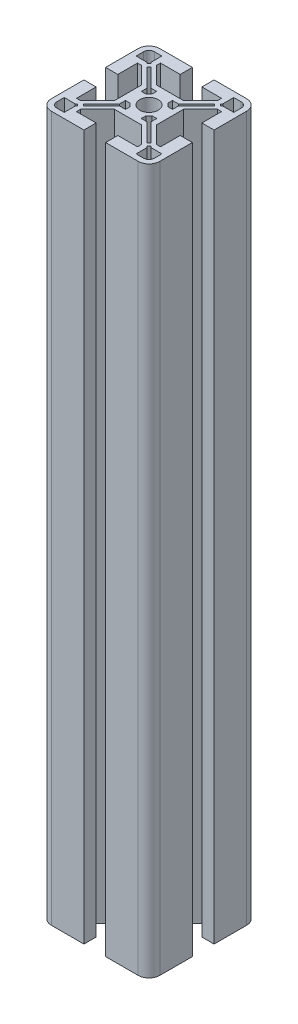
from build123d import *

# Parameters (mm, degrees)
BOSS_EXTRUDE1_DEPTH = 130


with BuildPart() as part:
    # Sketch1 → Boss-Extrude1 (new body, symmetric)
    with BuildSketch(Plane(origin=(0, 0, 0), x_dir=(1, 0, 0), z_dir=(0, 1, 0))):
        with BuildLine():
            Line((-27.932619, -6.859853), (-27.932619, 5.140147))
            ThreePointArc((-27.932619, 5.140147), (-26.761046, 7.968574), (-23.932619, 9.140147))
            Line((-23.932619, 9.140147), (-11.932619, 9.140147))
            Line((-11.932619, 9.140147), (-11.932619, 4.640147))
            Line((-11.932619, 4.640147), (-19.182619, 4.640147))
            Line((-19.182619, 4.640147), (-19.182619, 3.140147))
            Line((-19.182619, 3.140147), (-12.932619, -3.109853))
            Line((-12.932619, -3.109853), (-7.932619, -3.109853))
            Line((-7.932619, -3.109853), (-2.932619, -3.109853))
            Line((-2.932619, -3.109853), (3.317381, 3.140147))
            Line((3.317381, 3.140147), (3.317381, 4.640147))
            Line((3.317381, 4.640147), (-3.932619, 4.640147))
            Line((-3.932619, 4.640147), (-3.932619, 9.140147))
            Line((-3.932619, 9.140147), (8.067381, 9.140147))
            ThreePointArc((8.067381, 9.140147), (10.895808, 7.968574), (12.067381, 5.140147))
            Line((12.067381, 5.140147), (12.067381, -6.859853))
            Line((12.067381, -6.859853), (7.567381, -6.859853))
            Line((7.567381, -6.859853), (7.567381, 0.390147))
            Line((7.567381, 0.390147), (6.067381, 0.390147))
            Line((6.067381, 0.390147), (-0.182619, -5.859853))
            Line((-0.182619, -5.859853), (-0.182619, -10.859853))
            Line((-0.182619, -10.859853), (-0.182619, -15.859853))
            Line((-0.182619, -15.859853), (6.067381, -22.109853))
            Line((6.067381, -22.109853), (7.567381, -22.109853))
            Line((7.567381, -22.109853), (7.567381, -14.859853))
            Line((7.567381, -14.859853), (12.067381, -14.859853))
            Line((12.067381, -14.859853), (12.067381, -26.859853))
            ThreePointArc((12.067381, -26.859853), (10.895808, -29.68828), (8.067381, -30.859853))
            Line((8.067381, -30.859853), (-3.932619, -30.859853))
            Line((-3.932619, -30.859853), (-3.932619, -26.359853))
            Line((-3.932619, -26.359853), (3.317381, -26.359853))
            Line((3.317381, -26.359853), (3.317381, -24.859853))
            Line((3.317381, -24.859853), (-2.932619, -18.609853))
            Line((-2.932619, -18.609853), (-7.932619, -18.609853))
            Line((-7.932619, -18.609853), (-12.932619, -18.609853))
            Line((-12.932619, -18.609853), (-19.182619, -24.859853))
            Line((-19.182619, -24.859853), (-19.182619, -26.359853))
            Line((-19.182619, -26.359853), (-11.932619, -26.359853))
            Line((-11.932619, -26.359853), (-11.932619, -30.859853))
            Line((-11.932619, -30.859853), (-23.932619, -30.859853))
            ThreePointArc((-23.932619, -30.859853), (-26.761046, -29.68828), (-27.932619, -26.859853))
            Line((-27.932619, -26.859853), (-27.932619, -14.859853))
            Line((-27.932619, -14.859853), (-23.432619, -14.859853))
            Line((-23.432619, -14.859853), (-23.432619, -22.109853))
            Line((-23.432619, -22.109853), (-21.932619, -22.109853))
            Line((-21.932619, -22.109853), (-15.682619, -15.859853))
            Line((-15.682619, -15.859853), (-15.682619, -10.859853))
            Line((-15.682619, -10.859853), (-15.682619, -5.859853))
            Line((-15.682619, -5.859853), (-21.932619, 0.390147))
            Line((-21.932619, 0.390147), (-23.432619, 0.390147))
            Line((-23.432619, 0.390147), (-23.432619, -6.859853))
            Line((-23.432619, -6.859853), (-27.932619, -6.859853))
        make_face()
        with BuildLine():
            Line((-25.932619, 2.390147), (-25.932619, 5.140147))
            ThreePointArc((-25.932619, 5.140147), (-25.346832, 6.554361), (-23.932619, 7.140147))
            Line((-23.932619, 7.140147), (-21.182619, 7.140147))
            Line((-21.182619, 7.140147), (-21.182619, 3.097254))
            Line((-21.182619, 3.097254), (-20.734396, 2.649031))
            Line((-20.734396, 2.649031), (-21.441502, 1.941924))
            Line((-21.441502, 1.941924), (-21.889726, 2.390147))
            Line((-21.889726, 2.390147), (-25.932619, 2.390147))
        make_face(mode=Mode.SUBTRACT)
        with BuildLine():
            Line((-20.380842, 0.881264), (-13.682619, -5.816959))
            Line((-13.682619, -5.816959), (-13.682619, -7.955115))
            Line((-13.682619, -7.955115), (-13.182619, -7.955115))
            Line((-13.182619, -7.955115), (-12.002324, -7.955115))
            ThreePointArc((-12.002324, -7.955115), (-11.468153, -7.324319), (-10.837356, -6.790148))
            Line((-10.837356, -6.790148), (-10.837356, -5.609853))
            Line((-10.837356, -5.609853), (-10.837356, -5.109853))
            Line((-10.837356, -5.109853), (-12.975512, -5.109853))
            Line((-12.975512, -5.109853), (-19.673735, 1.588371))
            Line((-19.673735, 1.588371), (-20.380842, 0.881264))
        make_face(mode=Mode.SUBTRACT)
        with BuildLine():
            Line((10.067381, 2.390147), (10.067381, 5.140147))
            ThreePointArc((10.067381, 5.140147), (9.481595, 6.554361), (8.067381, 7.140147))
            Line((8.067381, 7.140147), (5.317381, 7.140147))
            Line((5.317381, 7.140147), (5.317381, 3.097254))
            Line((5.317381, 3.097254), (4.869158, 2.649031))
            Line((4.869158, 2.649031), (5.576265, 1.941924))
            Line((5.576265, 1.941924), (6.024488, 2.390147))
            Line((6.024488, 2.390147), (10.067381, 2.390147))
        make_face(mode=Mode.SUBTRACT)
        with BuildLine():
            Line((-2.182619, -5.816959), (-2.182619, -7.955115))
            Line((-2.182619, -7.955115), (-2.682619, -7.955115))
            Line((-2.682619, -7.955115), (-3.862914, -7.955115))
            ThreePointArc((-3.862914, -7.955115), (-4.397085, -7.324319), (-5.027881, -6.790148))
            Line((-5.027881, -6.790148), (-5.027881, -5.609853))
            Line((-5.027881, -5.609853), (-5.027881, -5.109853))
            Line((-5.027881, -5.109853), (-2.889726, -5.109853))
            Line((-2.889726, -5.109853), (3.808498, 1.588371))
            Line((3.808498, 1.588371), (4.515604, 0.881264))
            Line((4.515604, 0.881264), (-2.182619, -5.816959))
        make_face(mode=Mode.SUBTRACT)
        with BuildLine():
            Line((5.317381, -28.859853), (8.067381, -28.859853))
            ThreePointArc((8.067381, -28.859853), (9.481595, -28.274066), (10.067381, -26.859853))
            Line((10.067381, -26.859853), (10.067381, -24.109853))
            Line((10.067381, -24.109853), (6.024488, -24.109853))
            Line((6.024488, -24.109853), (5.576265, -23.661629))
            Line((5.576265, -23.661629), (4.869158, -24.368736))
            Line((4.869158, -24.368736), (5.317381, -24.816959))
            Line((5.317381, -24.816959), (5.317381, -28.859853))
        make_face(mode=Mode.SUBTRACT)
        with BuildLine():
            Line((-2.889726, -16.609853), (-5.027881, -16.609853))
            Line((-5.027881, -16.609853), (-5.027881, -16.109853))
            Line((-5.027881, -16.109853), (-5.027881, -14.929558))
            ThreePointArc((-5.027881, -14.929558), (-4.397085, -14.395387), (-3.862914, -13.76459))
            Line((-3.862914, -13.76459), (-2.682619, -13.76459))
            Line((-2.682619, -13.76459), (-2.182619, -13.76459))
            Line((-2.182619, -13.76459), (-2.182619, -15.902746))
            Line((-2.182619, -15.902746), (4.515604, -22.600969))
            Line((4.515604, -22.600969), (3.808498, -23.308076))
            Line((3.808498, -23.308076), (-2.889726, -16.609853))
        make_face(mode=Mode.SUBTRACT)
        with BuildLine():
            Line((-25.932619, -24.109853), (-25.932619, -26.859853))
            ThreePointArc((-25.932619, -26.859853), (-25.346832, -28.274066), (-23.932619, -28.859853))
            Line((-23.932619, -28.859853), (-21.182619, -28.859853))
            Line((-21.182619, -28.859853), (-21.182619, -24.816959))
            Line((-21.182619, -24.816959), (-20.734396, -24.368736))
            Line((-20.734396, -24.368736), (-21.441502, -23.661629))
            Line((-21.441502, -23.661629), (-21.889726, -24.109853))
            Line((-21.889726, -24.109853), (-25.932619, -24.109853))
        make_face(mode=Mode.SUBTRACT)
        with BuildLine():
            Line((-13.682619, -15.902746), (-13.682619, -13.76459))
            Line((-13.682619, -13.76459), (-13.182619, -13.76459))
            Line((-13.182619, -13.76459), (-12.002324, -13.76459))
            ThreePointArc((-12.002324, -13.76459), (-11.468153, -14.395387), (-10.837356, -14.929558))
            Line((-10.837356, -14.929558), (-10.837356, -16.109853))
            Line((-10.837356, -16.109853), (-10.837356, -16.609853))
            Line((-10.837356, -16.609853), (-12.975512, -16.609853))
            Line((-12.975512, -16.609853), (-19.673735, -23.308076))
            Line((-19.673735, -23.308076), (-20.380842, -22.600969))
            Line((-20.380842, -22.600969), (-13.682619, -15.902746))
        make_face(mode=Mode.SUBTRACT)
        with BuildLine():
            ThreePointArc((-11.332619, -10.859853), (-10.336782, -8.45569), (-7.932619, -7.459853))
            ThreePointArc((-7.932619, -7.459853), (-5.528456, -8.45569), (-4.532619, -10.859853))
            ThreePointArc((-4.532619, -10.859853), (-5.528456, -13.264016), (-7.932619, -14.259853))
            ThreePointArc((-7.932619, -14.259853), (-10.336782, -13.264016), (-11.332619, -10.859853))
        make_face(mode=Mode.SUBTRACT)
    extrude(amount=BOSS_EXTRUDE1_DEPTH, both=True)


solid = part.part
